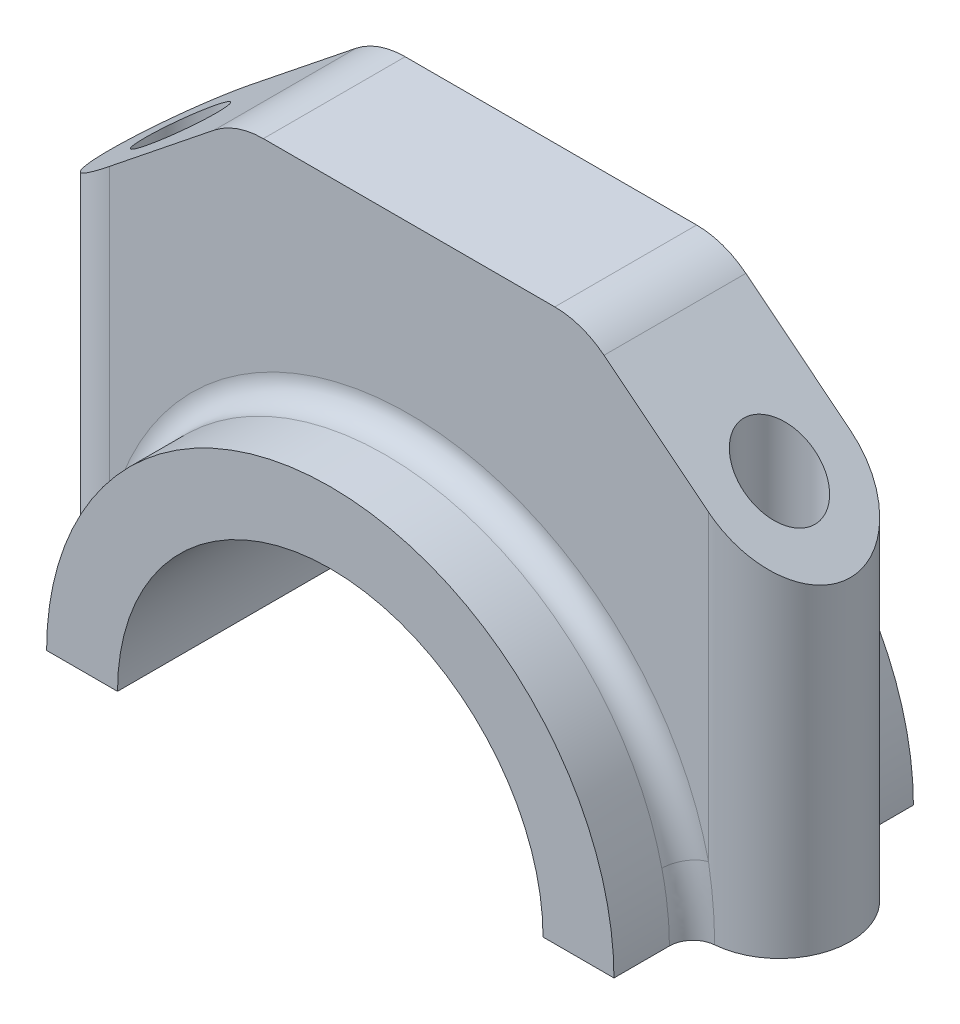
from build123d import *

# Parameters (mm, degrees)
BOSS_EXTRUDE1_DEPTH = 38
SKETCH3_R           = 4.5
BOSS_EXTRUDE2_DEPTH = 60
CUT_EXTRUDE1_DEPTH  = 60
CUT_EXTRUDE2_DEPTH  = 60
FILLET1_R           = 10
FILLET2_R           = 3


with BuildPart() as part:
    # Sketch2 → Boss-Extrude1 (new body)
    with BuildSketch(Plane.XY):
        with BuildLine():
            Line((-36, 0), (-27, 0))
            ThreePointArc((-27, 0), (0, 27), (27, 0))
            Line((27, 0), (36, 0))
            ThreePointArc((36, 0), (0, 36), (-36, 0))
        make_face()
    extrude(amount=BOSS_EXTRUDE1_DEPTH)

    # Sketch3 → Boss-Extrude2 (add)
    with BuildSketch(Plane(origin=(0, 60, 0), x_dir=(-1, 0, 0), z_dir=(0, -1, 0))):
        with BuildLine():
            Line((38, -28), (-38, -28))
            ThreePointArc((-38, -28), (-47, -19), (-38, -10))
            Line((-38, -10), (38, -10))
            ThreePointArc((38, -10), (47, -19), (38, -28))
        make_face()
        with Locations((38, -19)):
            Circle(SKETCH3_R, mode=Mode.SUBTRACT)
        with Locations((-38, -19)):
            Circle(SKETCH3_R, mode=Mode.SUBTRACT)
    extrude(amount=BOSS_EXTRUDE2_DEPTH)

    # Sketch4 → Cut-Extrude1 (cut)
    with BuildSketch(Plane.XY.offset(28)):
        with BuildLine():
            Line((-27, 0), (27, 0))
            ThreePointArc((27, 0), (0, 27), (-27, 0))
        make_face()
    extrude(amount=-CUT_EXTRUDE1_DEPTH, mode=Mode.SUBTRACT)

    # Sketch5 → Cut-Extrude2 (cut)
    with BuildSketch(Plane.XY.offset(28)):
        Polygon((-47, 40), (-22, 60), (-47, 60), align=None)
        Polygon((47, 40), (22, 60), (47, 60), align=None)
    extrude(amount=-CUT_EXTRUDE2_DEPTH, mode=Mode.SUBTRACT)

    # Fillet1
    fillet1_edges = [part.edges().sort_by_distance(p)[0] for p in [
        (-22, 60, 19),
        (22, 60, 19),
    ]]
    fillet(fillet1_edges, radius=FILLET1_R)

    # Fillet2
    fillet2_edges = [part.edges().sort_by_distance(p)[0] for p in [
        (0, 36, 10),
        (0, 36, 28),
    ]]
    fillet(fillet2_edges, radius=FILLET2_R)


solid = part.part
